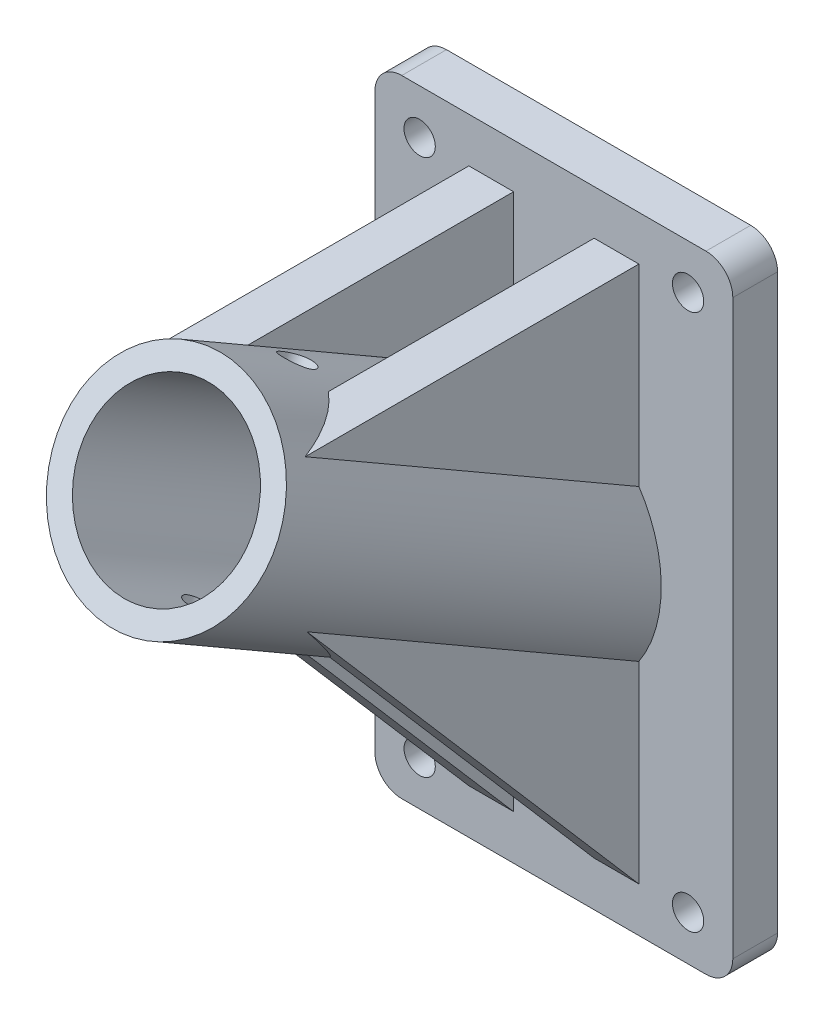
from build123d import *

# Parameters (mm, degrees)
EXTRUDE_1_DEPTH                      = 5
EXTRUDE_2_REACH                      = 92.62
EXTRUDE_START                        = -50
SKETCH_2_R                           = 12
CUT_EXTRUDE_1_REACH                  = 69.832
SKETCH_4_R                           = 1.7500000000000004
FILLET_1_R                           = 3
EXTRUDE_START_2                      = 7
EXTRUDE_3_DEPTH                      = 2.5
EXTRUDE_START_3                      = -7
EXTRUDE_4_DEPTH                      = 2.5
SKETCH_5_R                           = 9.4
CUT_EXTRUDE_2_DEPTH                  = 80.58022808394182
CUT_EXTRUDE_3_REACH                  = 65.9
CUT_EXTRUDE_3_END_RADIUS             = 12
SKETCH_7_R                           = 1.7500000000000004
SKETCH_7_R_2                         = 1.7500000000000009
CUT_EXTRUDE_3_DIRECTION_2_REACH      = 65.9
CUT_EXTRUDE_3_DIRECTION_2_END_RADIUS = 12


with BuildPart() as part:
    # ｽｹｯﾁ1 → ﾎﾞｽ - 押し出し1 (new body)
    with BuildSketch(Plane.XY):
        Polygon((-20.000000000000004, 35), (19.999999999999996, 35), (20.000000000000004, -35), (-19.999999999999996, -35), align=None)
    extrude(amount=-EXTRUDE_1_DEPTH)

    # ｽｹｯﾁ2 → ﾎﾞｽ - 押し出し2 (add, up to next)
    with BuildSketch(Plane(origin=(0, 0, 0), x_dir=(1, 0, 0), z_dir=(0, -0.49999999999999495, -0.8660254037844416)).offset(EXTRUDE_START), mode=Mode.PRIVATE) as extrude_2_sk1:
        Circle(SKETCH_2_R)
    extrude_2_tool1 = extrude(extrude_2_sk1.sketch, amount=EXTRUDE_2_REACH, mode=Mode.PRIVATE) - part.part
    add(extrude_2_tool1.solids().sort_by_distance((0, 25, 43.30127))[0])

    # ｽｹｯﾁ4 → ｶｯﾄ - 押し出し1 (cut, up to next)
    with BuildSketch(Plane(origin=(0, 0, -5), x_dir=(-1, 0, 0), z_dir=(0, 0, -1)), mode=Mode.PRIVATE) as cut_extrude_1_sk1:
        with Locations((-15.000000000000004, 30)):
            Circle(SKETCH_4_R)
    cut_extrude_1_tool1 = extrude(cut_extrude_1_sk1.sketch, amount=-CUT_EXTRUDE_1_REACH, mode=Mode.PRIVATE) & part.part
    # ｽｹｯﾁ4 → ｶｯﾄ - 押し出し1 (cut, up to next)
    with BuildSketch(Plane(origin=(0, 0, -5), x_dir=(-1, 0, 0), z_dir=(0, 0, -1)), mode=Mode.PRIVATE) as cut_extrude_1_sk2:
        with Locations((15.000000000000004, 29.999999999999986)):
            Circle(SKETCH_4_R)
    cut_extrude_1_tool2 = extrude(cut_extrude_1_sk2.sketch, amount=-CUT_EXTRUDE_1_REACH, mode=Mode.PRIVATE) & part.part
    # ｽｹｯﾁ4 → ｶｯﾄ - 押し出し1 (cut, up to next)
    with BuildSketch(Plane(origin=(0, 0, -5), x_dir=(-1, 0, 0), z_dir=(0, 0, -1)), mode=Mode.PRIVATE) as cut_extrude_1_sk3:
        with Locations((15.000000000000004, -29.999999999999986)):
            Circle(SKETCH_4_R)
    cut_extrude_1_tool3 = extrude(cut_extrude_1_sk3.sketch, amount=-CUT_EXTRUDE_1_REACH, mode=Mode.PRIVATE) & part.part
    # ｽｹｯﾁ4 → ｶｯﾄ - 押し出し1 (cut, up to next)
    with BuildSketch(Plane(origin=(0, 0, -5), x_dir=(-1, 0, 0), z_dir=(0, 0, -1)), mode=Mode.PRIVATE) as cut_extrude_1_sk4:
        with Locations((-15.000000000000004, -30)):
            Circle(SKETCH_4_R)
    cut_extrude_1_tool4 = extrude(cut_extrude_1_sk4.sketch, amount=-CUT_EXTRUDE_1_REACH, mode=Mode.PRIVATE) & part.part
    add(cut_extrude_1_tool1.solids().sort_by_distance((15, 30, -5))[0], mode=Mode.SUBTRACT)
    add(cut_extrude_1_tool2.solids().sort_by_distance((-15, 30, -5))[0], mode=Mode.SUBTRACT)
    add(cut_extrude_1_tool3.solids().sort_by_distance((-15, -30, -5))[0], mode=Mode.SUBTRACT)
    add(cut_extrude_1_tool4.solids().sort_by_distance((15, -30, -5))[0], mode=Mode.SUBTRACT)

    # ﾌｨﾚｯﾄ1
    fillet_1_edges = [part.edges().sort_by_distance(p)[0] for p in [
        (19.999999999999996, 35, -2.5),
        (-20.000000000000004, 35, -2.5),
        (-19.999999999999996, -35, -2.5),
        (20.000000000000004, -35, -2.5),
    ]]
    fillet(fillet_1_edges, radius=FILLET_1_R)

    # ｽｹｯﾁ6 → ﾎﾞｽ - 押し出し3 (add, symmetric)
    with BuildSketch(Plane(origin=(0, 0, 0), x_dir=(0, 0, -1), z_dir=(1, 0, 0)).offset(EXTRUDE_START_2)):
        Polygon((0, 30), (-38, 29.999999999999996), (-38, 13.999999999999998), (0, -30.000000000000004), align=None)
    extrude(amount=EXTRUDE_3_DEPTH, both=True)

    # ｽｹｯﾁ6<2> → ﾎﾞｽ - 押し出し4 (add, symmetric)
    with BuildSketch(Plane(origin=(0, 0, 0), x_dir=(0, 0, -1), z_dir=(1, 0, 0)).offset(EXTRUDE_START_3)):
        Polygon((0, 30), (-38, 29.999999999999996), (-38, 13.999999999999998), (0, -30.000000000000004), align=None)
    extrude(amount=EXTRUDE_4_DEPTH, both=True)

    # ｽｹｯﾁ5 → ｶｯﾄ - 押し出し2 (cut, through all)
    with BuildSketch(Plane(origin=(0, 24.999999999999744, 43.30127018922208), x_dir=(1, 0, 0), z_dir=(0, 0.49999999999999495, 0.8660254037844416))):
        Circle(SKETCH_5_R)
    extrude(amount=-CUT_EXTRUDE_2_DEPTH, mode=Mode.SUBTRACT)

    # ｶｯﾄ - 押し出し3: up to this cylinder (the profile starts inside it)
    cut_extrude_3_end = Plane(origin=(0, 14.999999950838543, 25.98076202838338), z_dir=(0, 0.4999999999999949, 0.8660254037844416)) * Cylinder(CUT_EXTRUDE_3_END_RADIUS, 176.7999999344516, mode=Mode.PRIVATE)
    # ｽｹｯﾁ7 → ｶｯﾄ - 押し出し3 (cut, up to the surface)
    with BuildSketch(Plane(origin=(0, 0, 0), x_dir=(1, 0, 0), z_dir=(0, 0.8660254037844416, -0.49999999999999495)), mode=Mode.PRIVATE) as cut_extrude_3_sk1:
        with Locations((2.45e-15, -20)):
            Circle(SKETCH_7_R)
    cut_extrude_3_tool1 = extrude(cut_extrude_3_sk1.sketch, amount=-CUT_EXTRUDE_3_REACH, mode=Mode.PRIVATE) & cut_extrude_3_end
    add(cut_extrude_3_tool1.solids().sort_by_distance((0, 10, 17.320508))[0], mode=Mode.SUBTRACT)
    # ｽｹｯﾁ7 → ｶｯﾄ - 押し出し3 (cut, up to the surface)
    with BuildSketch(Plane(origin=(0, 0, 0), x_dir=(1, 0, 0), z_dir=(0, 0.8660254037844416, -0.49999999999999495)), mode=Mode.PRIVATE) as cut_extrude_3_sk2:
        with Locations((4.9e-15, -40)):
            Circle(SKETCH_7_R_2)
    cut_extrude_3_tool2 = extrude(cut_extrude_3_sk2.sketch, amount=-CUT_EXTRUDE_3_REACH, mode=Mode.PRIVATE) & cut_extrude_3_end
    add(cut_extrude_3_tool2.solids().sort_by_distance((0, 20, 34.641016))[0], mode=Mode.SUBTRACT)

    # ｶｯﾄ - 押し出し3 direction 2: up to this cylinder (the profile starts inside it)
    cut_extrude_3_direction_2_end = Plane(origin=(0, 14.999999950838543, 25.98076202838338), z_dir=(0, 0.4999999999999949, 0.8660254037844416)) * Cylinder(CUT_EXTRUDE_3_DIRECTION_2_END_RADIUS, 176.7999999344516, mode=Mode.PRIVATE)
    # ｽｹｯﾁ7 → ｶｯﾄ - 押し出し3 direction 2 (cut, up to the surface)
    with BuildSketch(Plane(origin=(0, 0, 0), x_dir=(1, 0, 0), z_dir=(0, 0.8660254037844416, -0.49999999999999495)), mode=Mode.PRIVATE) as cut_extrude_3_direction_2_sk1:
        with Locations((2.45e-15, -20)):
            Circle(SKETCH_7_R)
    cut_extrude_3_direction_2_tool1 = extrude(cut_extrude_3_direction_2_sk1.sketch, amount=CUT_EXTRUDE_3_DIRECTION_2_REACH, mode=Mode.PRIVATE) & cut_extrude_3_direction_2_end
    add(cut_extrude_3_direction_2_tool1.solids().sort_by_distance((0, 10, 17.320508))[0], mode=Mode.SUBTRACT)
    # ｽｹｯﾁ7 → ｶｯﾄ - 押し出し3 direction 2 (cut, up to the surface)
    with BuildSketch(Plane(origin=(0, 0, 0), x_dir=(1, 0, 0), z_dir=(0, 0.8660254037844416, -0.49999999999999495)), mode=Mode.PRIVATE) as cut_extrude_3_direction_2_sk2:
        with Locations((4.9e-15, -40)):
            Circle(SKETCH_7_R_2)
    cut_extrude_3_direction_2_tool2 = extrude(cut_extrude_3_direction_2_sk2.sketch, amount=CUT_EXTRUDE_3_DIRECTION_2_REACH, mode=Mode.PRIVATE) & cut_extrude_3_direction_2_end
    add(cut_extrude_3_direction_2_tool2.solids().sort_by_distance((0, 20, 34.641016))[0], mode=Mode.SUBTRACT)


solid = part.part
